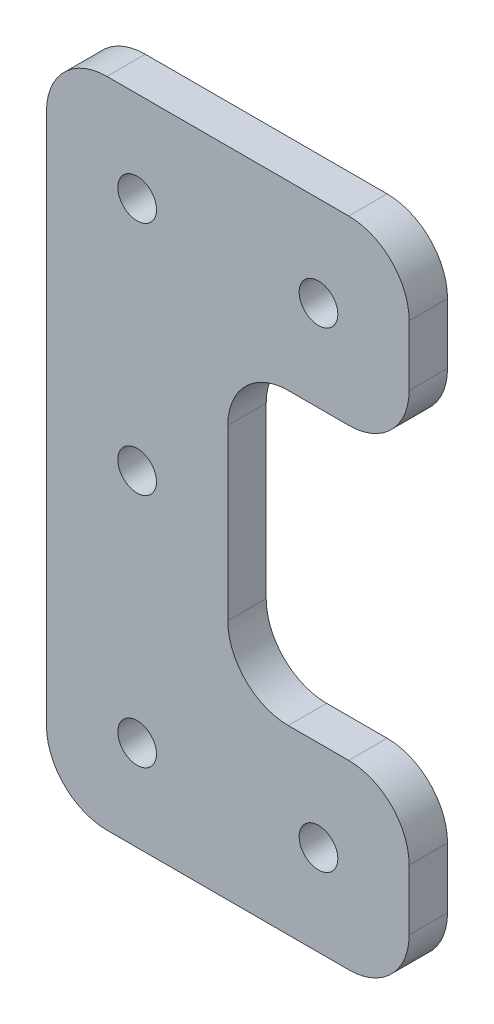
from build123d import *

# Parameters (mm, degrees)
BOSS_EXTRUDE1_DEPTH = 3.175
FILLET1_R           = 5
SKETCH2_R           = 1.6
CUT_EXTRUDE1_DEPTH  = 4.175


with BuildPart() as part:
    # Sketch1 → Boss-Extrude1 (new body)
    with BuildSketch(Plane.XY):
        Polygon((0, 54), (0, 0), (30, 0), (30, 15), (15, 15), (15, 39), (30, 39), (30, 54), align=None)
    extrude(amount=BOSS_EXTRUDE1_DEPTH)

    # Fillet1
    fillet1_edges = [part.edges().sort_by_distance(p)[0] for p in [
        (15, 15, 1.5875),
        (30, 15, 1.5875),
        (30, 0, 1.5875),
        (0, 0, 1.5875),
        (0, 54, 1.5875),
        (30, 54, 1.5875),
        (30, 39, 1.5875),
        (15, 39, 1.5875),
    ]]
    fillet(fillet1_edges, radius=FILLET1_R)

    # Sketch2 → Cut-Extrude1 (cut, through all)
    with BuildSketch(Plane.XY.offset(3.175)):
        with Locations((7.5, 7.5)):
            Circle(SKETCH2_R)
        with Locations((7.5, 46.5)):
            Circle(SKETCH2_R)
        with Locations((22.5, 7.5)):
            Circle(SKETCH2_R)
        with Locations((7.5, 27)):
            Circle(SKETCH2_R)
        with Locations((22.5, 46.5)):
            Circle(SKETCH2_R)
    extrude(amount=-CUT_EXTRUDE1_DEPTH, mode=Mode.SUBTRACT)


solid = part.part
